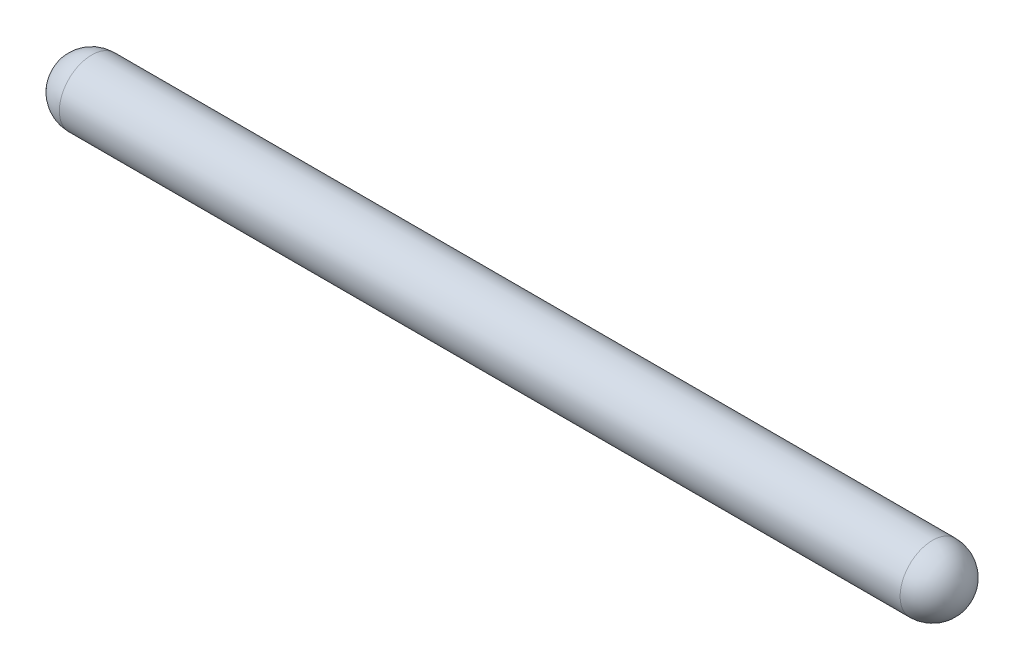
from build123d import *

# Parameters (mm, degrees)
SKETCH_2_W         = 65
SKETCH_2_H         = 2.5
DOME_3_FACE_RADIUS = 2.5
DOME_3_HEIGHT      = 2.5
DOME_4_FACE_RADIUS = 2.5
DOME_4_HEIGHT      = 2.5


with BuildPart() as part:
    # Sketch 2 → Revolve 2 (revolve)
    with BuildSketch(Plane.XY):
        with Locations((3.5, 1.25)):
            Rectangle(SKETCH_2_W, SKETCH_2_H)
    revolve(axis=Axis((-29, 0, 0), (1, 0, 0)))

    # Dome 3: a dome of height H over a round flat face of radius A is a cap of a sphere of radius (A * A + H * H) / (2 * H)
    dome_3_r = (DOME_3_FACE_RADIUS * DOME_3_FACE_RADIUS + DOME_3_HEIGHT * DOME_3_HEIGHT) / (2 * DOME_3_HEIGHT)
    dome_3_base = Plane((36, 0, 0), z_dir=(1, 0, 0))
    with Locations(dome_3_base.offset(DOME_3_HEIGHT - dome_3_r)):
        dome_3_ball = Sphere(dome_3_r, mode=Mode.PRIVATE)
    add(split(dome_3_ball, bisect_by=dome_3_base, keep=Keep.TOP, mode=Mode.PRIVATE))

    # Dome 4: a dome of height H over a round flat face of radius A is a cap of a sphere of radius (A * A + H * H) / (2 * H)
    dome_4_r = (DOME_4_FACE_RADIUS * DOME_4_FACE_RADIUS + DOME_4_HEIGHT * DOME_4_HEIGHT) / (2 * DOME_4_HEIGHT)
    dome_4_base = Plane((-29, 0, 0), z_dir=(-1, 0, 0))
    with Locations(dome_4_base.offset(DOME_4_HEIGHT - dome_4_r)):
        dome_4_ball = Sphere(dome_4_r, mode=Mode.PRIVATE)
    add(split(dome_4_ball, bisect_by=dome_4_base, keep=Keep.TOP, mode=Mode.PRIVATE))


solid = part.part
